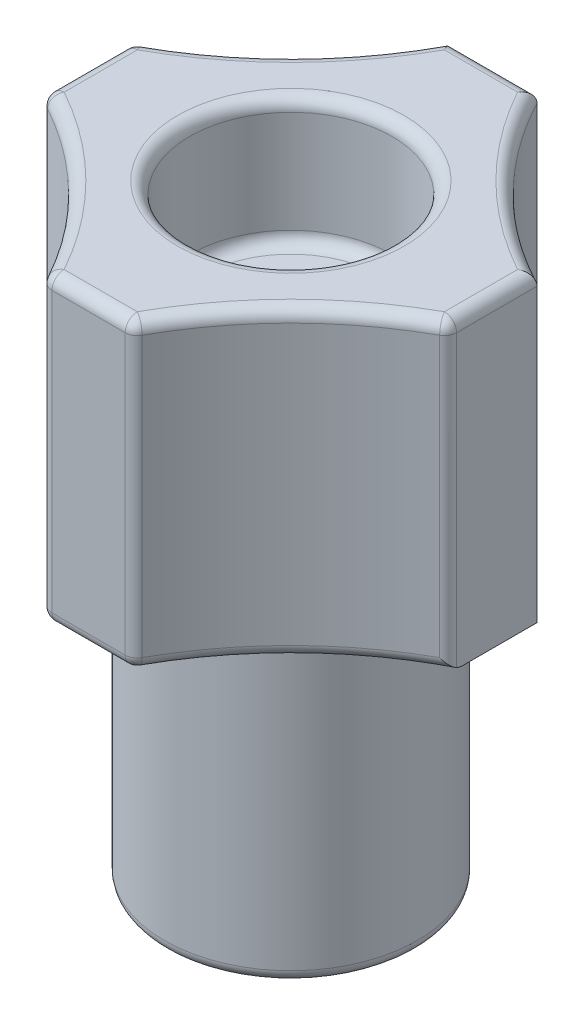
from build123d import *

# Parameters (mm, degrees)
SKETCH1_W           = 12.7
SKETCH1_H           = 12.7
BOSS_EXTRUDE1_DEPTH = 9.525
SKETCH3_R           = 11.90625
CUT_EXTRUDE1_DEPTH  = 14.090860361
CIRPATTERN1_COUNT   = 4
SKETCH4_R           = 3.96875
BOSS_EXTRUDE2_DEPTH = 9.525
SKETCH5_R           = 1.5875
CUT_EXTRUDE2_DEPTH  = 22.060567419
SKETCH6_R           = 3.175
CUT_EXTRUDE3_DEPTH  = 3.96875
FILLET3_R           = 0.381


with BuildPart() as part:
    # Sketch1 → Boss-Extrude1 (new body)
    with BuildSketch(Plane(origin=(0, 0, 0), x_dir=(1, 0, 0), z_dir=(0, 1, 0))):
        Rectangle(SKETCH1_W, SKETCH1_H)
    extrude(amount=BOSS_EXTRUDE1_DEPTH)

    # Sketch3 → Cut-Extrude1 (cut, through all)
    with BuildSketch(Plane(origin=(0, 9.525, 0), x_dir=(1, 0, 0), z_dir=(0, 1, 0))):
        with Locations((11.90625, 11.90625)):
            Circle(SKETCH3_R)
    cut_extrude1 = extrude(amount=-CUT_EXTRUDE1_DEPTH, mode=Mode.SUBTRACT)

    # CirPattern1: Cut-Extrude1 ×4 about axis
    cirpattern1_axis = Axis((0, 50, 0), (0, -1, 0))
    for i in range(1, CIRPATTERN1_COUNT):
        add(cut_extrude1.rotate(cirpattern1_axis, i * 360 / CIRPATTERN1_COUNT), mode=Mode.SUBTRACT)

    # Sketch4 → Boss-Extrude2 (add)
    with BuildSketch(Plane.XZ):
        Circle(SKETCH4_R)
    extrude(amount=BOSS_EXTRUDE2_DEPTH)

    # Sketch5 → Cut-Extrude2 (cut, through all)
    with BuildSketch(Plane(origin=(0, 9.525, 0), x_dir=(1, 0, 0), z_dir=(0, 1, 0))):
        Circle(SKETCH5_R)
    extrude(amount=-CUT_EXTRUDE2_DEPTH, mode=Mode.SUBTRACT)

    # Sketch6 → Cut-Extrude3 (cut)
    with BuildSketch(Plane(origin=(0, 9.525, 0), x_dir=(1, 0, 0), z_dir=(0, 1, 0))):
        Circle(SKETCH6_R)
    extrude(amount=-CUT_EXTRUDE3_DEPTH, mode=Mode.SUBTRACT)

    # Fillet3
    fillet3_edges = [part.edges().sort_by_distance(p)[0] for p in [
        (-3.175, 9.525, 0),
        (-3.175, 5.55625, 0),
        (-1.5875, 5.55625, 0),
        (-1.5875, -9.525, 0),
        (-3.96875, -9.525, 0),
        (-3.487259886, 9.525, -3.487259886),
        (-6.35, 4.7625, -1.375966291),
        (-3.487259886, 0, 3.487259886),
        (-3.487259886, 9.525, 3.487259886),
        (-1.375966291, 4.7625, 6.35),
        (-6.35, 4.7625, 1.375966291),
        (3.487259886, 9.525, 3.487259886),
        (3.487259886, 0, 3.487259886),
        (1.375966291, 4.7625, 6.35),
        (6.35, 4.7625, 1.375966291),
        (3.487259886, 9.525, -3.487259886),
        (-6.35, 0, 0),
        (0, 0, 6.35),
        (6.35, 9.525, 0),
        (0, 9.525, -6.35),
        (-6.35, 9.525, 0),
        (0, 9.525, 6.35),
        (-3.96875, 0, 0),
    ]]
    fillet(fillet3_edges, radius=FILLET3_R)


solid = part.part
